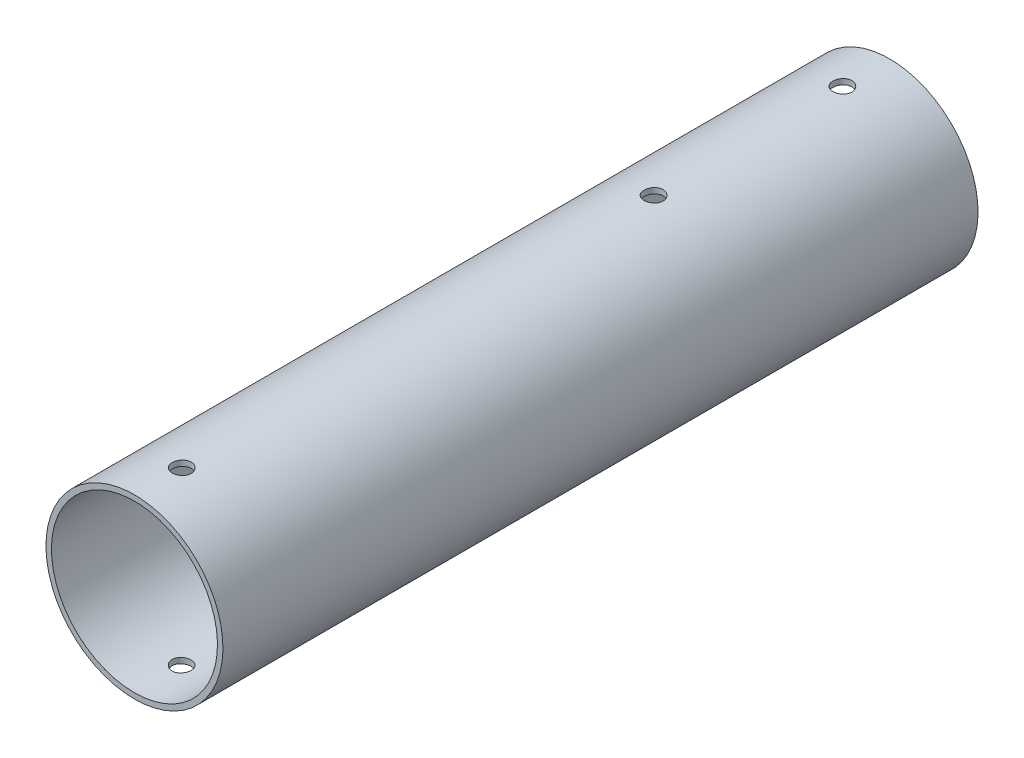
from build123d import *

# Parameters (mm, degrees)
SKETCH3_W               = 203.2
SKETCH3_H               = 1.4732
SKETCH4_R               = 2.5527
CUT_EXTRUDE1_DEPTH      = 24.8125
CUT_EXTRUDE1_DEPTH_BACK = 24.8125
CUT_EXTRUDE2_DEPTH      = 24.8125001


with BuildPart() as part:
    # Sketch3 → Revolve1 (revolve)
    with BuildSketch(Plane(origin=(0, 0, 0), x_dir=(0, 0, -1), z_dir=(1, 0, 0))):
        with Locations((0, 23.0759)):
            Rectangle(SKETCH3_W, SKETCH3_H)
    revolve(axis=Axis((0, 0, 101.6), (0, 0, -1)))

    # Sketch4 → Cut-Extrude1 (cut, two sides)
    with BuildSketch(Plane(origin=(0, 0, 0), x_dir=(1, 0, 0), z_dir=(0, 1, 0))) as cut_extrude1_sk:
        with Locations((0, 88.9)):
            Circle(SKETCH4_R)
        with Locations((0, 38.1)):
            Circle(SKETCH4_R)
        with Locations((0, -88.9)):
            Circle(SKETCH4_R)
    extrude(amount=CUT_EXTRUDE1_DEPTH, mode=Mode.SUBTRACT)
    extrude(cut_extrude1_sk.sketch, amount=-CUT_EXTRUDE1_DEPTH_BACK, mode=Mode.SUBTRACT)

    # Sketch5 → Cut-Extrude2 (cut, through all)
    with BuildSketch(Plane(origin=(0, 0, 0), x_dir=(1, 0, 0), z_dir=(0, 1, 0))):
        with BuildLine():
            Line((9.525, -19.05), (-9.525, -19.05))
            ThreePointArc((-9.525, -19.05), (-11.77006403, -18.12006403), (-12.7, -15.875))
            Line((-12.7, -15.875), (-12.7, 15.875))
            ThreePointArc((-12.7, 15.875), (-11.77006403, 18.12006403), (-9.525, 19.05))
            Line((-9.525, 19.05), (9.525, 19.05))
            ThreePointArc((9.525, 19.05), (11.77006403, 18.12006403), (12.7, 15.875))
            Line((12.7, 15.875), (12.7, -15.875))
            ThreePointArc((12.7, -15.875), (11.77006403, -18.12006403), (9.525, -19.05))
        make_face()
    extrude(amount=-CUT_EXTRUDE2_DEPTH, mode=Mode.SUBTRACT)


solid = part.part
